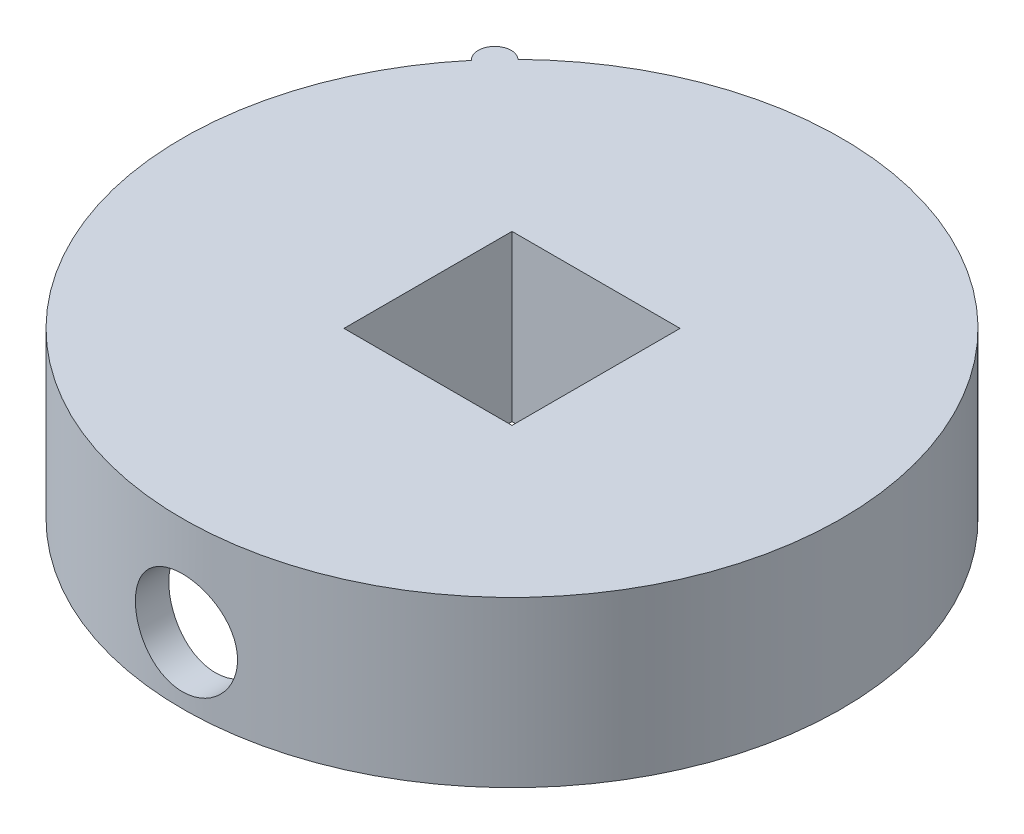
from build123d import *

# Parameters (mm, degrees)
SKETCH1_R           = 20
BOSS_EXTRUDE1_DEPTH = 10
SKETCH2_W           = 10.2
SKETCH2_H           = 10.2
CUT_EXTRUDE2_DEPTH  = 11
SHELL3_T            = -2
SKETCH3_R           = 3.1
CUT_EXTRUDE3_DEPTH  = 13.9
BOSS_EXTRUDE2_DEPTH = 10


with BuildPart() as part:
    # Sketch1 → Boss-Extrude1 (new body)
    with BuildSketch(Plane(origin=(0, 0, 0), x_dir=(1, 0, 0), z_dir=(0, 1, 0))):
        Circle(SKETCH1_R)
    extrude(amount=BOSS_EXTRUDE1_DEPTH)

    # Sketch2 → Cut-Extrude2 (cut, through all)
    with BuildSketch(Plane.XZ):
        Rectangle(SKETCH2_W, SKETCH2_H)
    extrude(amount=-CUT_EXTRUDE2_DEPTH, mode=Mode.SUBTRACT)

    # Shell3
    shell3_openings = [part.faces().sort_by_distance(p)[0] for p in [
        (0, 0, 0),
    ]]
    offset(amount=SHELL3_T, openings=shell3_openings, kind=Kind.INTERSECTION)

    # Sketch3 → Cut-Extrude3 (cut, through all)
    with BuildSketch(Plane.XY.offset(7.1)):
        with Locations((0, 4)):
            Circle(SKETCH3_R)
    extrude(amount=CUT_EXTRUDE3_DEPTH, mode=Mode.SUBTRACT)

    # Sketch4 → Boss-Extrude2 (add)
    with BuildSketch(Plane(origin=(0, 10, 0), x_dir=(1, 0, 0), z_dir=(0, 1, 0))):
        with BuildLine():
            Line((-13.960317173, 14.321646009), (-15.320888862, 12.855752194))
            ThreePointArc((-15.320888862, 12.855752194), (-15.373549926, 14.268984946), (-13.960317173, 14.321646009))
        make_face()
    extrude(amount=-BOSS_EXTRUDE2_DEPTH)


solid = part.part
